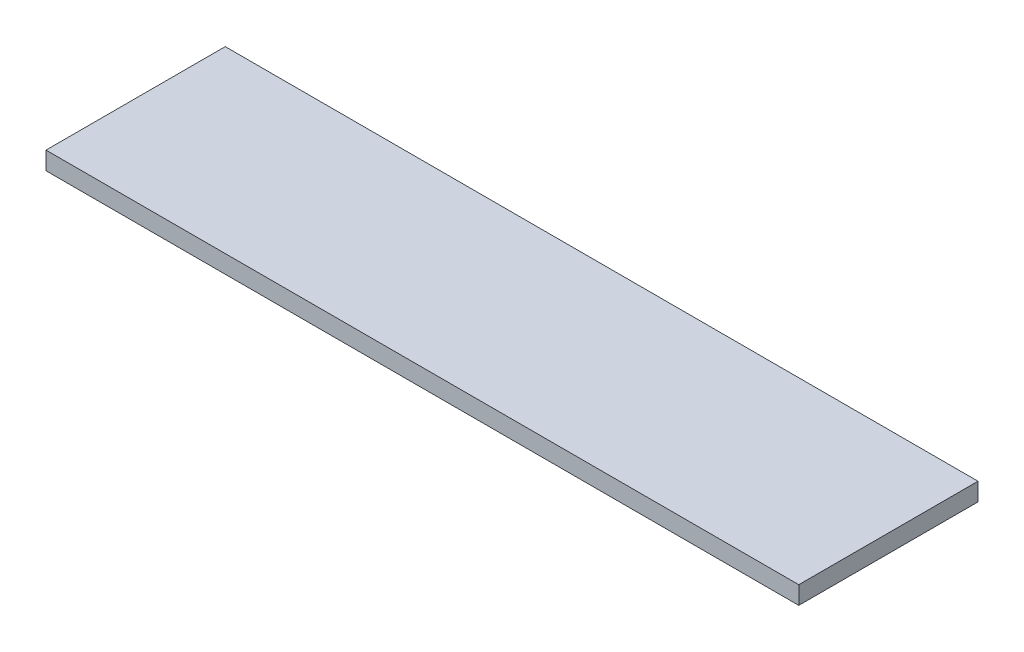
from build123d import *

# Parameters (mm, degrees)
SKETCH_1_W      = 42
SKETCH_1_H      = 10
EXTRUDE_1_DEPTH = 1


with BuildPart() as part:
    # Эскиз1 → Бобышка-Вытянуть1 (new body)
    with BuildSketch(Plane(origin=(0, 0, 0), x_dir=(1, 0, 0), z_dir=(0, 1, 0))):
        with Locations((21, 5)):
            Rectangle(SKETCH_1_W, SKETCH_1_H)
    extrude(amount=EXTRUDE_1_DEPTH)


solid = part.part
